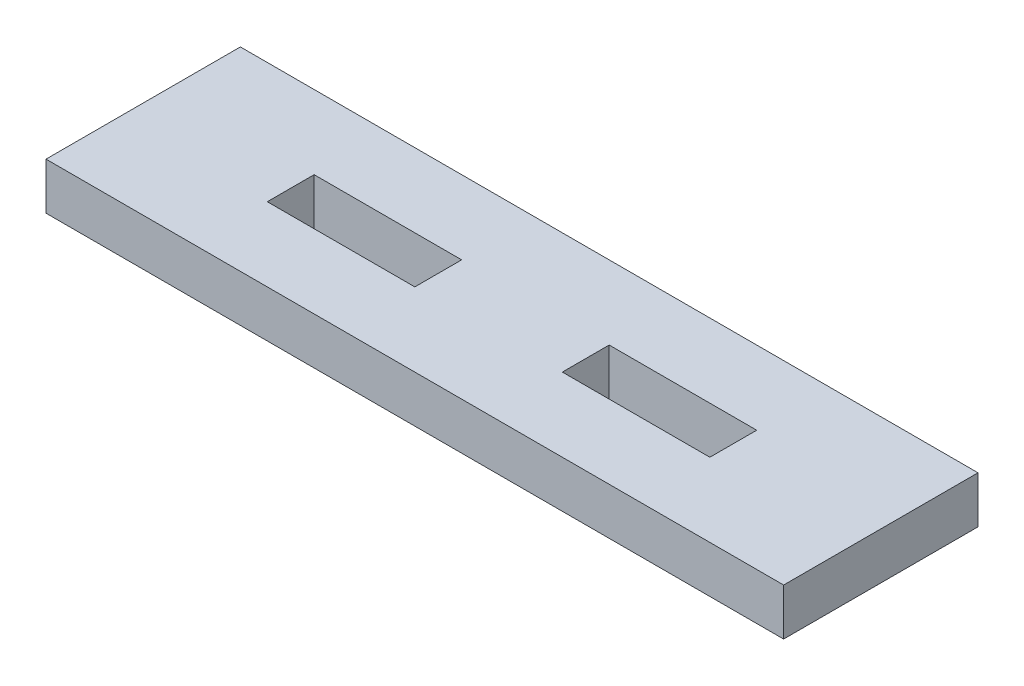
from build123d import *

# Parameters (mm, degrees)
SKETCH1_W           = 50
SKETCH1_H           = 13.175
SKETCH1_W_2         = 10
SKETCH1_H_2         = 3.175
BOSS_EXTRUDE1_DEPTH = 3.175


with BuildPart() as part:
    # Sketch1 → Boss-Extrude1 (new body)
    with BuildSketch(Plane(origin=(0, 0, 0), x_dir=(1, 0, 0), z_dir=(0, 1, 0))):
        with Locations((25, 6.5875)):
            Rectangle(SKETCH1_W, SKETCH1_H)
        with Locations((35, 6.5875)):
            Rectangle(SKETCH1_W_2, SKETCH1_H_2, mode=Mode.SUBTRACT)
        with Locations((15, 6.5875)):
            Rectangle(SKETCH1_W_2, SKETCH1_H_2, mode=Mode.SUBTRACT)
    extrude(amount=BOSS_EXTRUDE1_DEPTH)


solid = part.part
